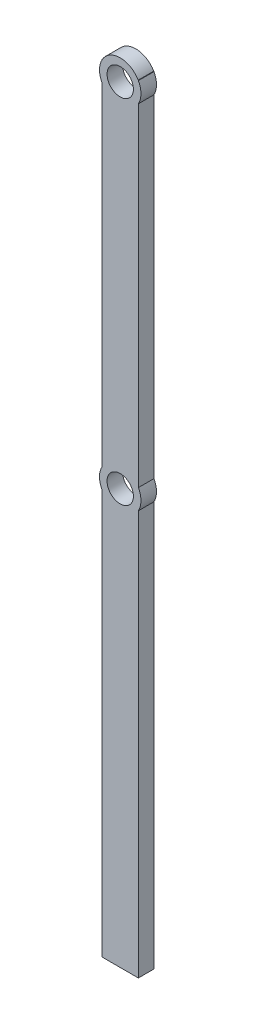
from build123d import *

# Parameters (mm, degrees)
SKETCH2_R           = 20
SKETCH2_R_2         = 12.7
BOSS_EXTRUDE1_DEPTH = 7.5
SKETCH4_W           = 35
SKETCH4_H           = 15
BOSS_EXTRUDE2_DEPTH = 400
SKETCH4_2_W         = 35
SKETCH4_2_H         = 15
BOSS_EXTRUDE3_DEPTH = 350
SKETCH5_R           = 12.7
CUT_EXTRUDE1_DEPTH  = 401.569906508
LPATTERN1_COUNT     = 2
LPATTERN1_PITCH     = 340


with BuildPart() as part:
    # Sketch2 → Boss-Extrude1 (new, symmetric)
    with BuildSketch(Plane.XY):
        Circle(SKETCH2_R)
        Circle(SKETCH2_R_2, mode=Mode.SUBTRACT)
    boss_extrude1 = extrude(amount=BOSS_EXTRUDE1_DEPTH, both=True)

    # Sketch4 → Boss-Extrude2 (add)
    with BuildSketch(Plane(origin=(0, 0, 0), x_dir=(1, 0, 0), z_dir=(0, 1, 0))):
        Rectangle(SKETCH4_W, SKETCH4_H)
    extrude(amount=-BOSS_EXTRUDE2_DEPTH)

    # Sketch4_2 → Boss-Extrude3 (add)
    with BuildSketch(Plane(origin=(0, 0, 0), x_dir=(1, 0, 0), z_dir=(0, 1, 0))):
        Rectangle(SKETCH4_2_W, SKETCH4_2_H)
    extrude(amount=BOSS_EXTRUDE3_DEPTH)

    # Sketch5 → Cut-Extrude1 (cut, symmetric)
    with BuildSketch(Plane.XY):
        Circle(SKETCH5_R)
    cut_extrude1 = extrude(amount=CUT_EXTRUDE1_DEPTH, both=True, mode=Mode.SUBTRACT)

    # LPattern1: Boss-Extrude1, Cut-Extrude1 ×2
    with Locations(*[(0, i * LPATTERN1_PITCH, 0) for i in range(1, LPATTERN1_COUNT)]):
        add(boss_extrude1)
        add(cut_extrude1, mode=Mode.SUBTRACT)


solid = part.part
